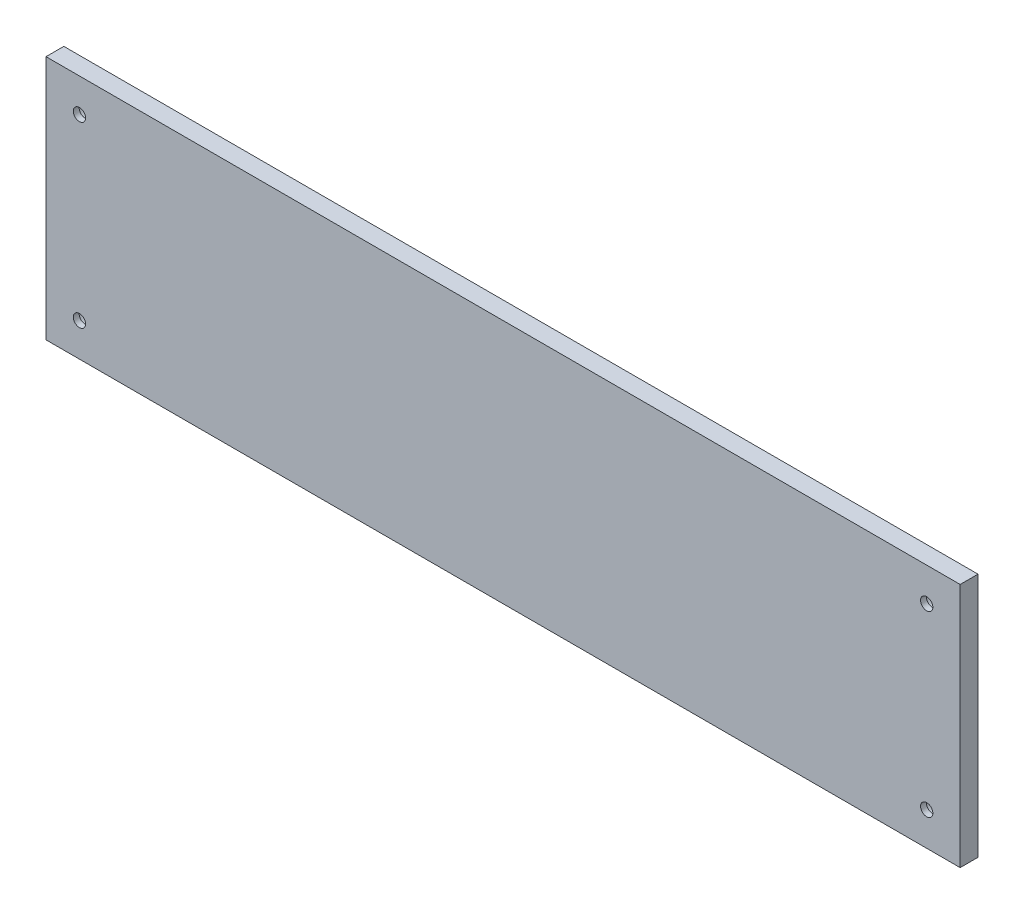
from build123d import *

# Parameters (mm, degrees)
SKETCH1_W                                           = 410
SKETCH1_H                                           = 110
EXTRUDE2_DEPTH                                      = 8
CBORE_FOR_M5_HEX_SOCKET_HEAD_CAP_SCREW1_D           = 5.5
CBORE_FOR_M5_HEX_SOCKET_HEAD_CAP_SCREW1_CBORE_D     = 10
CBORE_FOR_M5_HEX_SOCKET_HEAD_CAP_SCREW1_CBORE_DEPTH = 5.4


with BuildPart() as part:
    # Sketch1 → Extrude2 (new body)
    with BuildSketch(Plane.XY):
        with Locations((205, 55)):
            Rectangle(SKETCH1_W, SKETCH1_H)
    extrude(amount=EXTRUDE2_DEPTH)

    # CBORE for M5 Hex Socket Head Cap Screw1 (through all)
    with Locations(Plane(origin=(395, 95, 0), x_dir=(-1, 0, 0), z_dir=(0, 0, -1))):
        with Locations((0, 0), (380, 0), (380, -80), (0, -80)):
            CounterBoreHole(CBORE_FOR_M5_HEX_SOCKET_HEAD_CAP_SCREW1_D / 2, CBORE_FOR_M5_HEX_SOCKET_HEAD_CAP_SCREW1_CBORE_D / 2, CBORE_FOR_M5_HEX_SOCKET_HEAD_CAP_SCREW1_CBORE_DEPTH)


solid = part.part
